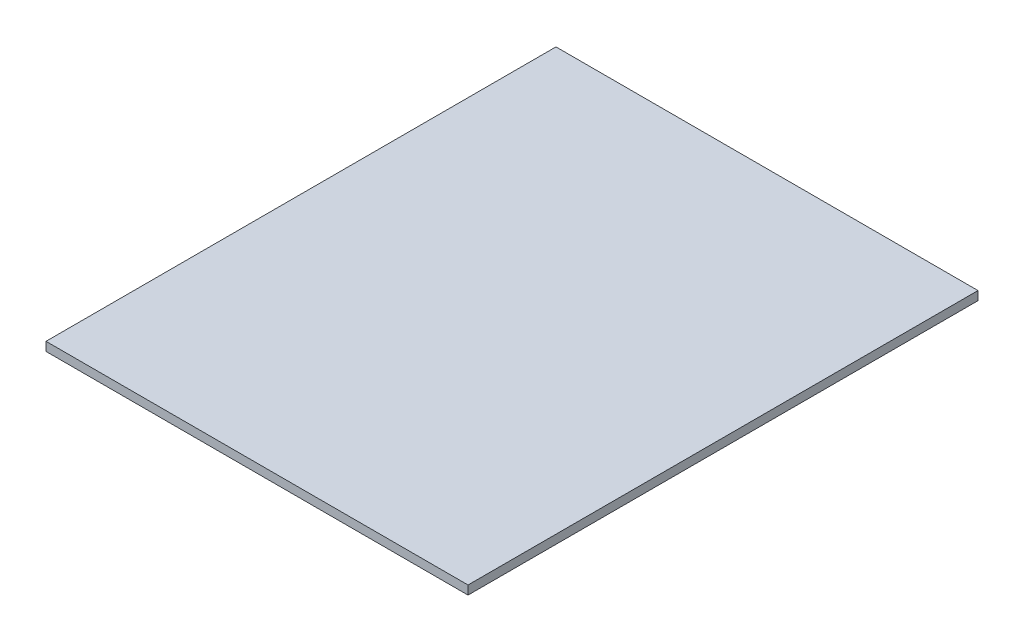
from build123d import *

# Parameters (mm, degrees)
SKETCH1_W           = 288
SKETCH1_H           = 348
BOSS_EXTRUDE1_DEPTH = 6


with BuildPart() as part:
    # Sketch1 → Boss-Extrude1 (new body)
    with BuildSketch(Plane(origin=(0, 0, 0), x_dir=(1, 0, 0), z_dir=(0, 1, 0))):
        with Locations((111.777306141, 159.011164947)):
            Rectangle(SKETCH1_W, SKETCH1_H)
    extrude(amount=BOSS_EXTRUDE1_DEPTH)


solid = part.part
